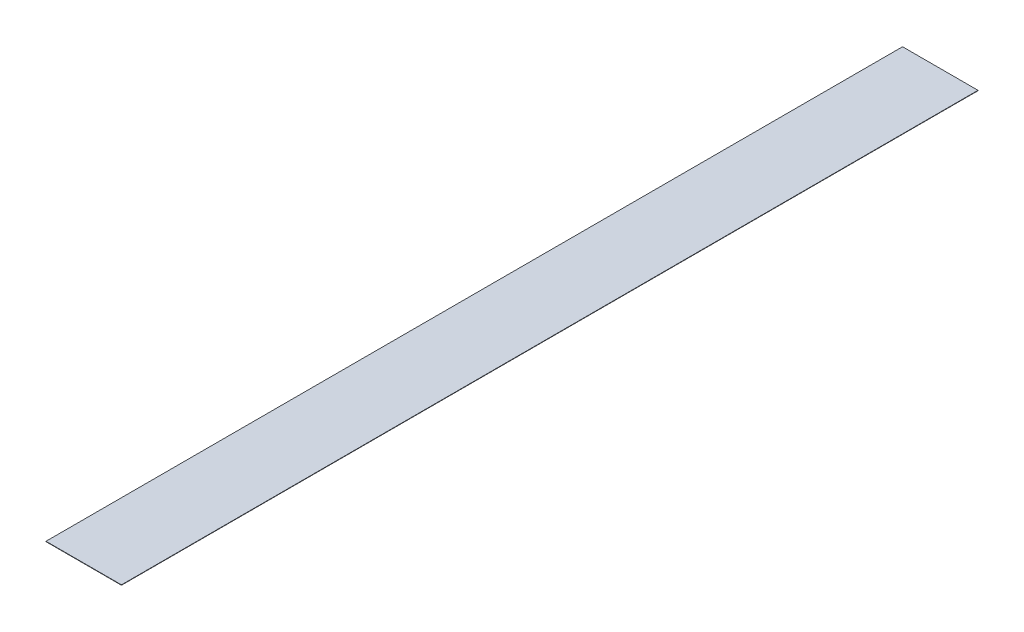
from build123d import *

# Parameters (mm, degrees)
SKETCH1_W           = 400
SKETCH1_H           = 4540
BOSS_EXTRUDE1_DEPTH = 2


with BuildPart() as part:
    # Sketch1 → Boss-Extrude1 (new body)
    with BuildSketch(Plane(origin=(0, 639.75, 0), x_dir=(1, 0, 0), z_dir=(0, 1, 0))):
        with Locations((-775, 0)):
            Rectangle(SKETCH1_W, SKETCH1_H)
    extrude(amount=BOSS_EXTRUDE1_DEPTH)


solid = part.part
